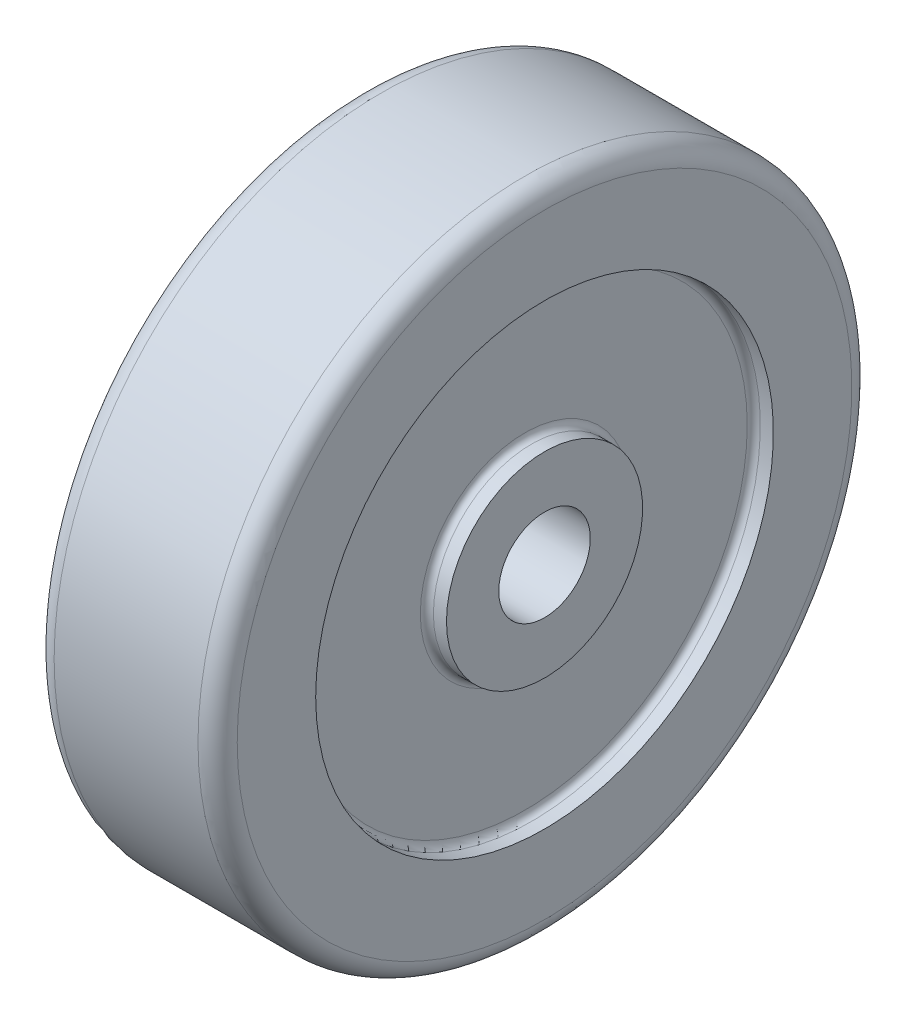
from build123d import *
from OCP.BRepFilletAPI import BRepFilletAPI_MakeFillet

# Parameters (mm, degrees)
REDONDEO1_R1 = 1
REDONDEO1_R2 = 3


with BuildPart() as part:
    # Croquis1 → Revolución2 (revolve)
    with BuildSketch(Plane.XY):
        Polygon((-14, 7), (14, 7), (14, 15), (11, 15), (11, 35), (14, 35), (14, 50), (-14, 50), (-14, 35), (-11, 35), (-11, 15), (-14, 15), align=None)
    revolve(axis=Axis((-38.038468992, 0, 0), (1, 0, 0)))

    # Redondeo1: one fillet with a radius per group of edges: ONE call of the kernel's fillet builder (fillet() takes one radius for all edges)
    redondeo1_edges_1 = [part.edges().sort_by_distance(p)[0] for p in [
        (11, -15, 0),
        (11, -35, 0),
        (-11, -35, 0),
        (-11, -15, 0),
    ]]
    redondeo1_edges_2 = [part.edges().sort_by_distance(p)[0] for p in [
        (14, -50, 0),
        (-14, -50, 0),
    ]]
    redondeo1 = BRepFilletAPI_MakeFillet(part.part.solid().wrapped)
    for e in redondeo1_edges_1:
        redondeo1.Add(REDONDEO1_R1, e.wrapped)
    for e in redondeo1_edges_2:
        redondeo1.Add(REDONDEO1_R2, e.wrapped)
    add(Compound.cast(redondeo1.Shape()), mode=Mode.REPLACE)


solid = part.part
